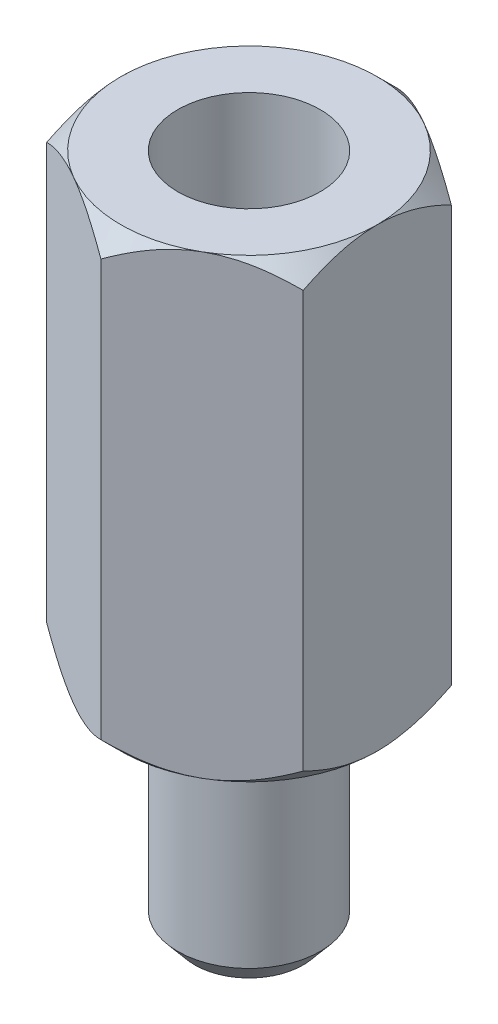
from build123d import *

# Parameters (mm, degrees)
SKETCH1_R           = 1.25
BOSS_EXTRUDE1_DEPTH = 3.9
BOSS_EXTRUDE2_DEPTH = 8
SKETCH3_R           = 1.25
CUT_EXTRUDE2_DEPTH  = 4.8
SKETCH4_OUTSIDE_W   = 35.048
SKETCH4_OUTSIDE_H   = 35.744
SKETCH4_OUTSIDE_R   = 2.25
CUT_EXTRUDE3_DEPTH  = 12.9
CUT_EXTRUDE3_TAPER  = 45
SKETCH5_OUTSIDE_W   = 27.248
SKETCH5_OUTSIDE_H   = 27.944
SKETCH5_OUTSIDE_R   = 2.25
CUT_EXTRUDE6_DEPTH  = 9
CUT_EXTRUDE6_TAPER  = 45
CHAMFER2_SIZE       = 0.3
CHAMFER2_SIZE2      = 0.357526078


with BuildPart() as part:
    # Sketch1 → Boss-Extrude1 (new body)
    with BuildSketch(Plane(origin=(0, 0, 0), x_dir=(1, 0, 0), z_dir=(0, 1, 0))):
        Circle(SKETCH1_R)
    extrude(amount=BOSS_EXTRUDE1_DEPTH)

    # Sketch2 → Boss-Extrude2 (add)
    with BuildSketch(Plane(origin=(0, 3.9, 0), x_dir=(1, 0, 0), z_dir=(0, 1, 0))):
        Polygon((0, 2.598076211), (-2.25, 1.299038106), (-2.25, -1.299038106), (0, -2.598076211), (2.25, -1.299038106), (2.25, 1.299038106), align=None)
    extrude(amount=BOSS_EXTRUDE2_DEPTH)

    # Sketch3 → Cut-Extrude2 (cut)
    with BuildSketch(Plane(origin=(0, 11.9, 0), x_dir=(1, 0, 0), z_dir=(0, 1, 0))):
        Circle(SKETCH3_R)
    extrude(amount=-CUT_EXTRUDE2_DEPTH, mode=Mode.SUBTRACT)

    # Sketch4 outside → Cut-Extrude3 (cut, through all)
    with BuildSketch(Plane(origin=(0, 11.9, 0), x_dir=(1, 0, 0), z_dir=(0, 1, 0))):
        Rectangle(SKETCH4_OUTSIDE_W, SKETCH4_OUTSIDE_H)
        Circle(SKETCH4_OUTSIDE_R, mode=Mode.SUBTRACT)
    extrude(amount=-CUT_EXTRUDE3_DEPTH, taper=CUT_EXTRUDE3_TAPER, mode=Mode.SUBTRACT)

    # Sketch5 outside → Cut-Extrude6 (cut, through all)
    with BuildSketch(Plane.XZ.offset(-3.9)):
        Rectangle(SKETCH5_OUTSIDE_W, SKETCH5_OUTSIDE_H)
        Circle(SKETCH5_OUTSIDE_R, mode=Mode.SUBTRACT)
    extrude(amount=-CUT_EXTRUDE6_DEPTH, taper=CUT_EXTRUDE6_TAPER, mode=Mode.SUBTRACT)

    # Chamfer2
    chamfer2_edges = [part.edges().sort_by_distance(p)[0] for p in [
        (-1.25, 0, 0),
    ]]
    chamfer2_side = [part.faces().sort_by_distance(p)[0] for p in [
        (0, 0, 0),
    ]]
    chamfer(chamfer2_edges, length=CHAMFER2_SIZE, length2=CHAMFER2_SIZE2, reference=chamfer2_side[0])


solid = part.part
